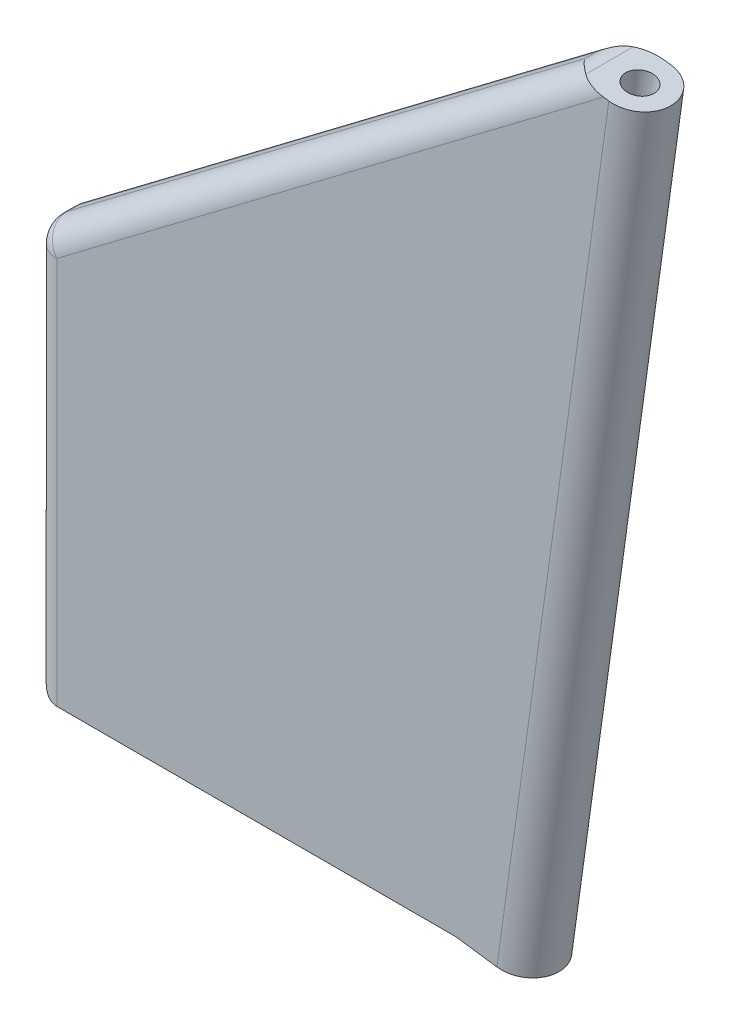
from build123d import *

# Parameters (mm, degrees)
SKETCH4_R           = 1.225
SKETCH4_R_2         = 0.56
BOSS_EXTRUDE1_DEPTH = 32
BOSS_EXTRUDE2_DEPTH = 1.225
SKETCH5_R           = 0.56
CUT_EXTRUDE1_DEPTH  = 32
FILLET1_R           = 1


with BuildPart() as part:
    # Sketch4 → Boss-Extrude1 (new body)
    with BuildSketch(Plane(origin=(24.384171153, 175.5596446, 0), x_dir=(-0.990491591, 0.137573282, 0), z_dir=(-0.137573282, -0.990491591, 0))):
        with Locations((15.494896665, 0)):
            Circle(SKETCH4_R)
        with Locations((15.494896665, 0)):
            Circle(SKETCH4_R_2, mode=Mode.SUBTRACT)
    extrude(amount=-BOSS_EXTRUDE1_DEPTH)

    # Sketch2 → Boss-Extrude2 (add, symmetric)
    with BuildSketch(Plane.XY):
        Polygon((-9.272942535, 193.66488497), (11.829402487, 209.610615887), (7.427057465, 177.91488497), (-9.272942535, 177.91488497), align=None)
        Polygon((9.036606301, 177.691328387), (13.438951323, 209.387059303), (11.829402487, 209.610615887), (7.427057465, 177.91488497), align=None)
    extrude(amount=BOSS_EXTRUDE2_DEPTH, both=True)

    # Sketch5 → Cut-Extrude1 (cut)
    with BuildSketch(Plane(origin=(24.384171153, 175.5596446, 0), x_dir=(0.990491591, -0.137573282, 0), z_dir=(-0.137573282, -0.990491591, 0))):
        with Locations((-15.494896665, 0)):
            Circle(SKETCH5_R)
    extrude(amount=-CUT_EXTRUDE1_DEPTH, mode=Mode.SUBTRACT)

    # Fillet1
    fillet1_edges = [part.edges().sort_by_distance(p)[0] for p in [
        (1.278229976, 201.637750428, 1.225),
        (11.829402487, 209.610615887, 0),
        (-9.272942535, 185.78988497, 1.225),
        (-9.272942535, 193.66488497, 0),
        (-9.272942535, 177.91488497, 0),
        (1.278229976, 201.637750428, -1.225),
        (-9.272942535, 185.78988497, -1.225),
    ]]
    fillet(fillet1_edges, radius=FILLET1_R)


solid = part.part
